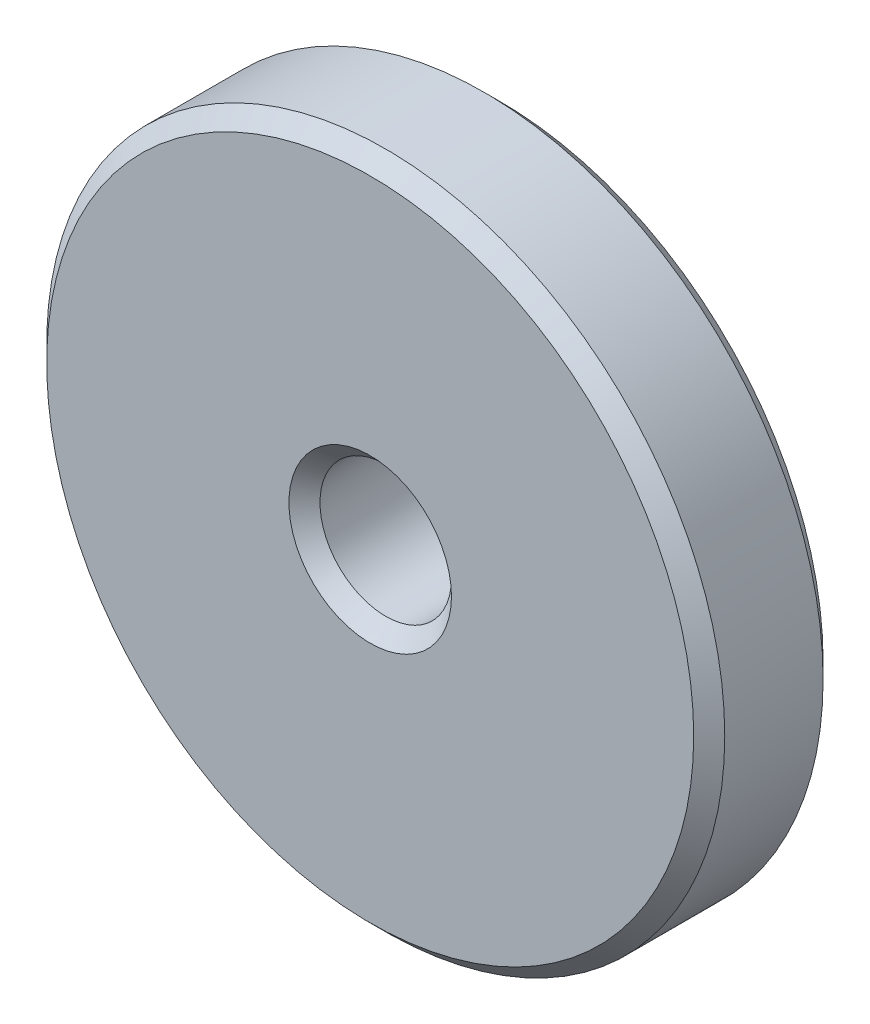
from build123d import *

# Parameters (mm, degrees)
SKETCH1_R           = 65.5
SKETCH1_R_2         = 12.7
BOSS_EXTRUDE1_DEPTH = 12.5
CHAMFER1_SIZE       = 3


with BuildPart() as part:
    # Sketch1 → Boss-Extrude1 (new body, symmetric)
    with BuildSketch(Plane.XY):
        Circle(SKETCH1_R)
        Circle(SKETCH1_R_2, mode=Mode.SUBTRACT)
    extrude(amount=BOSS_EXTRUDE1_DEPTH, both=True)

    # Chamfer1
    chamfer1_edges = [part.edges().sort_by_distance(p)[0] for p in [
        (-65.5, 0, -12.5),
        (-65.5, 0, 12.5),
        (-12.7, 0, -12.5),
        (-12.7, 0, 12.5),
    ]]
    chamfer(chamfer1_edges, length=CHAMFER1_SIZE)


solid = part.part
